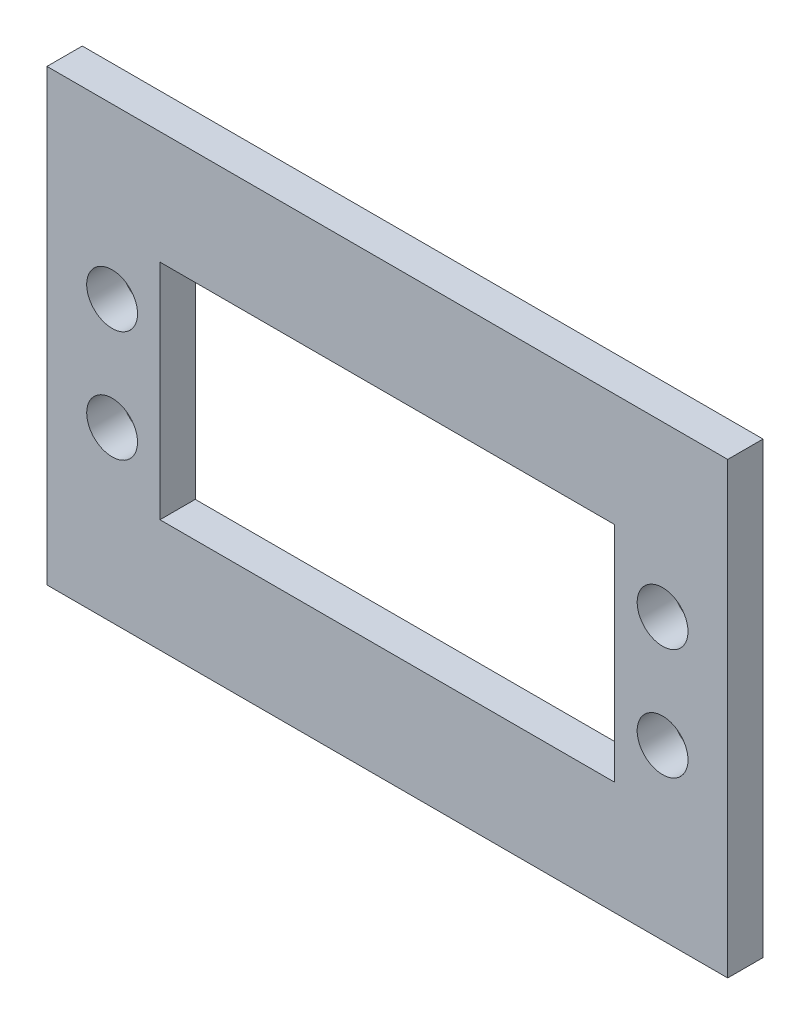
from build123d import *

# Parameters (mm, degrees)
SKETCH1_W           = 61.214
SKETCH1_H           = 40.386
SKETCH1_W_2         = 40.894
SKETCH1_H_2         = 20.066
BOSS_EXTRUDE1_DEPTH = 3.175
SKETCH2_R           = 2.286
CUT_EXTRUDE1_DEPTH  = 4.175


with BuildPart() as part:
    # Sketch1 → Boss-Extrude1 (new body)
    with BuildSketch(Plane.XY):
        with Locations((20.447, 10.033)):
            Rectangle(SKETCH1_W, SKETCH1_H)
        with Locations((20.447, 10.033)):
            Rectangle(SKETCH1_W_2, SKETCH1_H_2, mode=Mode.SUBTRACT)
    extrude(amount=BOSS_EXTRUDE1_DEPTH)

    # Sketch2 → Cut-Extrude1 (cut, through all)
    with BuildSketch(Plane.XY.offset(3.175)):
        with Locations((-4.303, 15.033)):
            Circle(SKETCH2_R)
        with Locations((-4.303, 5.033)):
            Circle(SKETCH2_R)
        with Locations((45.197, 5.033)):
            Circle(SKETCH2_R)
        with Locations((45.197, 15.033)):
            Circle(SKETCH2_R)
    extrude(amount=-CUT_EXTRUDE1_DEPTH, mode=Mode.SUBTRACT)


solid = part.part
